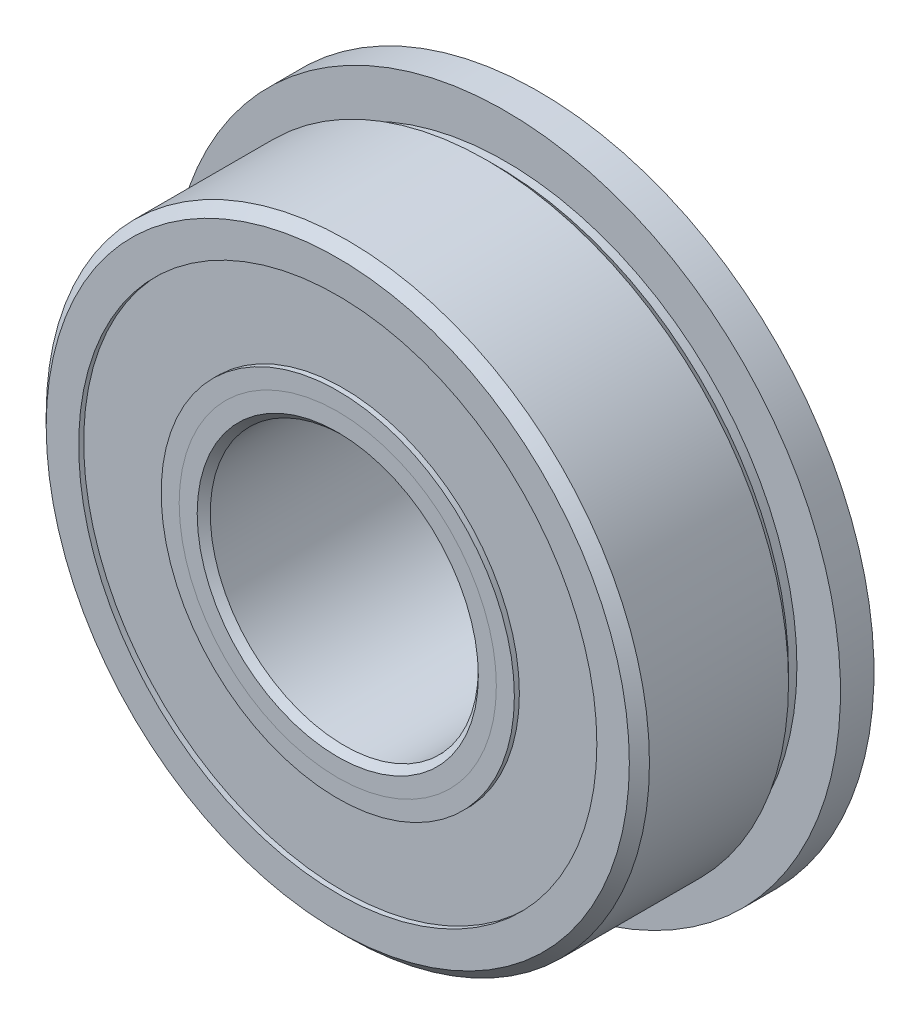
from build123d import *

# Parameters (mm, degrees)
SKETCH5_W          = 1.5875
SKETCH5_H          = 2.833076923
CIRPATTERN1_COUNT  = 12
SKETCH7_W          = 1.174197652
SKETCH7_H          = 3.907692308
SKETCH7_H_2        = 3.534996154
SKETCH9_R          = 7.956677
SKETCH9_R_2        = 7.607173
CUT_EXTRUDE1_DEPTH = 0.127
SKETCH10_R         = 9.436608
SKETCH10_R_2       = 8.7376
CUT_EXTRUDE2_DEPTH = 0.254


with BuildPart() as part:
    # Sketch8 → Revolve7 (revolve)
    with BuildSketch(Plane(origin=(0, 0, 0), x_dir=(0, 0, -1), z_dir=(1, 0, 0))):
        with BuildLine():
            Line((4.7625, 13.81125), (4.28625, 14.2875))
            Line((4.28625, 14.2875), (-4.28625, 14.2875))
            Line((-4.28625, 14.2875), (-4.7625, 13.81125))
            Line((-4.7625, 13.81125), (-4.7625, 12.272596154))
            Line((-4.7625, 12.272596154), (-2.721428571, 12.272596154))
            ThreePointArc((-2.721428571, 12.272596154), (0, 13.668927348), (2.721428571, 12.272596154))
            Line((2.721428571, 12.272596154), (4.7625, 12.272596154))
            Line((4.7625, 12.272596154), (4.7625, 13.81125))
        make_face()
    revolve(axis=Axis((0, 0, 4.7625), (0, 0, -1)))

    # Sketch5 → Revolve5 (revolve)
    with BuildSketch(Plane(origin=(0, 0, 0), x_dir=(0, 0, -1), z_dir=(1, 0, 0))):
        with Locations((3.96875, 14.458461539)):
            Rectangle(SKETCH5_W, SKETCH5_H)
    revolve(axis=Axis((0, 0, -6.35), (0, 0, 1)))

    # Sketch6 → Cut-Revolve1 (revolve, cut)
    with BuildSketch(Plane(origin=(0, 0, 0), x_dir=(0, 0, -1), z_dir=(1, 0, 0))):
        Polygon((2.301875, 14.2875), (2.778125, 13.81125), (3.175, 13.81125), (3.175, 14.2875), align=None)
    revolve(axis=Axis((0, 0, 4.7625), (0, 0, -1)), mode=Mode.SUBTRACT)


with BuildPart() as body_2:
    # Sketch2 → Revolve2 (revolve)
    with BuildSketch(Plane(origin=(0, 0, 0), x_dir=(0, 0, -1), z_dir=(1, 0, 0))):
        with BuildLine():
            Line((-4.7625, 8.364903846), (-2.721428571, 8.364903846))
            ThreePointArc((-2.721428571, 8.364903846), (-1.529371952, 7.338026985), (0, 6.968572652))
            Line((0, 6.968572652), (0, 6.659286326))
            Line((0, 6.659286326), (-3.90969124, 6.659286326))
            Line((-3.90969124, 6.659286326), (-4.7625, 7.512095086))
            Line((-4.7625, 7.512095086), (-4.7625, 8.364903846))
        make_face()
    revolve(axis=Axis((0, 0, 4.7625), (0, 0, -1)))


with BuildPart() as body_3:
    # Sketch3 → Revolve3 (revolve)
    with BuildSketch(Plane(origin=(0, 0, 0), x_dir=(0, 0, -1), z_dir=(1, 0, 0))):
        with BuildLine():
            Line((-4.7625, 7.512095086), (-3.90969124, 6.659286326))
            Line((-3.90969124, 6.659286326), (0, 6.659286326))
            Line((0, 6.659286326), (0, 6.968572652))
            ThreePointArc((0, 6.968572652), (1.721417345, 7.444656997), (2.953583068, 8.7376))
            Line((2.953583068, 8.7376), (6.35, 8.7376))
            Line((6.35, 8.7376), (6.35, 6.82625))
            Line((6.35, 6.82625), (5.87375, 6.35))
            Line((5.87375, 6.35), (-4.453213674, 6.35))
            Line((-4.453213674, 6.35), (-4.7625, 6.659286326))
            Line((-4.7625, 6.659286326), (-4.7625, 7.512095086))
        make_face()
    revolve(axis=Axis((0, 0, 4.7625), (0, 0, -1)))

    # Sketch9 → Cut-Extrude1 (cut)
    with BuildSketch(Plane(origin=(0, 0, -6.35), x_dir=(-1, 0, 0), z_dir=(0, 0, -1))):
        Circle(SKETCH9_R)
        Circle(SKETCH9_R_2, mode=Mode.SUBTRACT)
    extrude(amount=-CUT_EXTRUDE1_DEPTH, mode=Mode.SUBTRACT)


with BuildPart() as body_4:
    # Sketch4 → Revolve4 (revolve)
    with BuildSketch(Plane(origin=(0, 0, 0), x_dir=(0, 0, -1), z_dir=(1, 0, 0))):
        with BuildLine():
            Line((-3.350177348, 10.31875), (3.350177348, 10.31875))
            ThreePointArc((3.350177348, 10.31875), (0, 13.668927348), (-3.350177348, 10.31875))
        make_face()
    revolve(axis=Axis((0, 10.31875, 3.350177348), (0, 0, -1)))


with BuildPart() as cirpattern1_1:
    # CirPattern1: pattern copy
    add(body_4.part.rotate(Axis((0, 0, 4.7625), (0, 0, -1)), 1 * 360 / CIRPATTERN1_COUNT))


with BuildPart() as cirpattern1_2:
    # CirPattern1: pattern copy
    add(body_4.part.rotate(Axis((0, 0, 4.7625), (0, 0, -1)), 2 * 360 / CIRPATTERN1_COUNT))


with BuildPart() as cirpattern1_3:
    # CirPattern1: pattern copy
    add(body_4.part.rotate(Axis((0, 0, 4.7625), (0, 0, -1)), 3 * 360 / CIRPATTERN1_COUNT))


with BuildPart() as cirpattern1_4:
    # CirPattern1: pattern copy
    add(body_4.part.rotate(Axis((0, 0, 4.7625), (0, 0, -1)), 4 * 360 / CIRPATTERN1_COUNT))


with BuildPart() as cirpattern1_5:
    # CirPattern1: pattern copy
    add(body_4.part.rotate(Axis((0, 0, 4.7625), (0, 0, -1)), 5 * 360 / CIRPATTERN1_COUNT))


with BuildPart() as cirpattern1_6:
    # CirPattern1: pattern copy
    add(body_4.part.rotate(Axis((0, 0, 4.7625), (0, 0, -1)), 6 * 360 / CIRPATTERN1_COUNT))


with BuildPart() as cirpattern1_7:
    # CirPattern1: pattern copy
    add(body_4.part.rotate(Axis((0, 0, 4.7625), (0, 0, -1)), 7 * 360 / CIRPATTERN1_COUNT))


with BuildPart() as cirpattern1_8:
    # CirPattern1: pattern copy
    add(body_4.part.rotate(Axis((0, 0, 4.7625), (0, 0, -1)), 8 * 360 / CIRPATTERN1_COUNT))


with BuildPart() as cirpattern1_9:
    # CirPattern1: pattern copy
    add(body_4.part.rotate(Axis((0, 0, 4.7625), (0, 0, -1)), 9 * 360 / CIRPATTERN1_COUNT))


with BuildPart() as cirpattern1_10:
    # CirPattern1: pattern copy
    add(body_4.part.rotate(Axis((0, 0, 4.7625), (0, 0, -1)), 10 * 360 / CIRPATTERN1_COUNT))


with BuildPart() as cirpattern1_11:
    # CirPattern1: pattern copy
    add(body_4.part.rotate(Axis((0, 0, 4.7625), (0, 0, -1)), 11 * 360 / CIRPATTERN1_COUNT))


with BuildPart() as body_16:
    # Sketch7 → Revolve6 (revolve)
    with BuildSketch(Plane(origin=(0, 0, 0), x_dir=(0, 0, -1), z_dir=(1, 0, 0))):
        with Locations((-3.937276174, 10.31875)):
            Rectangle(SKETCH7_W, SKETCH7_H)
        with Locations((3.937276174, 10.505098077)):
            Rectangle(SKETCH7_W, SKETCH7_H_2)
    revolve(axis=Axis((0, 0, 4.7625), (0, 0, -1)))

    # Sketch10 → Cut-Extrude2 (cut)
    with BuildSketch(Plane(origin=(0, 0, -4.524375), x_dir=(-1, 0, 0), z_dir=(0, 0, -1))):
        Circle(SKETCH10_R)
        Circle(SKETCH10_R_2, mode=Mode.SUBTRACT)
    extrude(amount=-CUT_EXTRUDE2_DEPTH, mode=Mode.SUBTRACT)


solid = Compound([part.part, body_2.part, body_3.part, body_4.part, cirpattern1_1.part, cirpattern1_2.part, cirpattern1_3.part, cirpattern1_4.part, cirpattern1_5.part, cirpattern1_6.part, cirpattern1_7.part, cirpattern1_8.part, cirpattern1_9.part, cirpattern1_10.part, cirpattern1_11.part, body_16.part])
